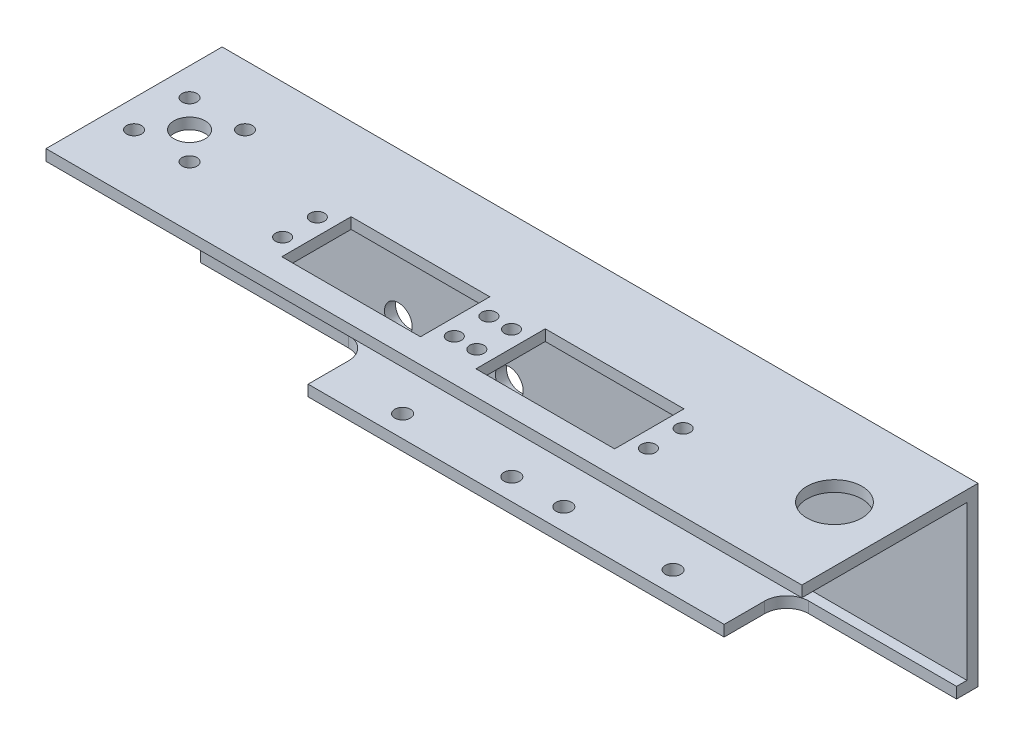
from build123d import *

# Parameters (mm, degrees)
BASE_ANGLE_PROFILE_DEPTH         = 109
SKETCH2_R                        = 2.05
SKETCH2_W                        = 40
SKETCH2_H                        = 20
SERVO_MOUNT_PATTERN_DEPTH        = 3.175
SKETCH3_R                        = 4.5
SKETCH3_R_2                      = 2.15
LEAD_SCREW_NUT_PATTERN_DEPTH     = 3.175
SKETCH4_R                        = 7.9375
SUPPORT_SHAFT_PASS_THROUGH_DEPTH = 3.175
CHANNEL_BOTTOM_CUT_DEPTH         = 10
SKETCH7_R                        = 4
CUT_EXTRUDE5_DEPTH               = 4.175
SKETCH8_R                        = 2.25
CUT_EXTRUDE6_DEPTH               = 3.175
FILLET1_R                        = 6.35
BODY_MOVE_COPY1_ANGLE            = 180


with BuildPart() as part:
    # Sketch1 → Base Angle Profile (new body, symmetric)
    with BuildSketch(Plane(origin=(0, 0, 0), x_dir=(0, 0, -1), z_dir=(1, 0, 0))):
        Polygon((0, 0), (50.8, 0), (50.8, -3.175), (3.175, -3.175), (3.175, -47.625), (50.8, -47.625), (50.8, -50.8), (0, -50.8), align=None)
    extrude(amount=BASE_ANGLE_PROFILE_DEPTH, both=True)

    # Sketch2 → Servo Mount Pattern (cut)
    with BuildSketch(Plane(origin=(0, 0, 0), x_dir=(1, 0, 0), z_dir=(0, 1, 0))):
        with Locations((-52.75, 38.8)):
            Circle(SKETCH2_R)
        with Locations((-52.75, 28.8)):
            Circle(SKETCH2_R)
        with Locations((-3.25, 38.8)):
            Circle(SKETCH2_R)
        with Locations((-3.25, 28.8)):
            Circle(SKETCH2_R)
        with Locations((3.25, 28.8)):
            Circle(SKETCH2_R)
        with Locations((3.25, 38.8)):
            Circle(SKETCH2_R)
        with Locations((52.75, 38.8)):
            Circle(SKETCH2_R)
        with Locations((52.75, 28.8)):
            Circle(SKETCH2_R)
        with Locations((-28, 33.8)):
            Rectangle(SKETCH2_W, SKETCH2_H)
        with Locations((28, 33.8)):
            Rectangle(SKETCH2_W, SKETCH2_H)
    extrude(amount=-SERVO_MOUNT_PATTERN_DEPTH, mode=Mode.SUBTRACT)

    # Sketch3 → Lead Screw Nut Pattern (cut)
    with BuildSketch(Plane(origin=(0, 0, 0), x_dir=(1, 0, 0), z_dir=(0, 1, 0))):
        with Locations((93, 25.4)):
            Circle(SKETCH3_R)
        with Locations((101, 33.4)):
            Circle(SKETCH3_R_2)
        with Locations((85, 33.4)):
            Circle(SKETCH3_R_2)
        with Locations((85, 17.4)):
            Circle(SKETCH3_R_2)
        with Locations((101, 17.4)):
            Circle(SKETCH3_R_2)
    extrude(amount=-LEAD_SCREW_NUT_PATTERN_DEPTH, mode=Mode.SUBTRACT)

    # Sketch4 → Support Shaft Pass Through (cut)
    with BuildSketch(Plane(origin=(0, 0, 0), x_dir=(1, 0, 0), z_dir=(0, 1, 0))):
        with Locations((-93, 25.4)):
            Circle(SKETCH4_R)
    extrude(amount=-SUPPORT_SHAFT_PASS_THROUGH_DEPTH, mode=Mode.SUBTRACT)

    # Sketch5 → Channel Bottom Cut (cut)
    with BuildSketch(Plane.XZ.offset(50.8)):
        Polygon((-109, -6.175), (-60, -6.175), (-60, -24.205), (60, -24.205), (60, -6.175), (109, -6.175), (109, -50.8), (-109, -50.8), align=None)
    extrude(amount=-CHANNEL_BOTTOM_CUT_DEPTH, mode=Mode.SUBTRACT)

    # Sketch7 → Cut-Extrude5 (cut, through all)
    with BuildSketch(Plane(origin=(0, 0, -3.175), x_dir=(-1, 0, 0), z_dir=(0, 0, -1))):
        with Locations((-55, -39.295)):
            Circle(SKETCH7_R)
        with Locations((-23, -39.295)):
            Circle(SKETCH7_R)
        with Locations((23, -39.295)):
            Circle(SKETCH7_R)
        with Locations((55, -39.295)):
            Circle(SKETCH7_R)
    extrude(amount=-CUT_EXTRUDE5_DEPTH, mode=Mode.SUBTRACT)

    # Sketch8 → Cut-Extrude6 (cut)
    with BuildSketch(Plane(origin=(0, -50.8, 0), x_dir=(-1, 0, 0), z_dir=(0, -1, 0))):
        with Locations((39, 17.955)):
            Circle(SKETCH8_R)
        with Locations((7.5, 17.955)):
            Circle(SKETCH8_R)
        with Locations((-7.5, 17.955)):
            Circle(SKETCH8_R)
        with Locations((-39, 17.955)):
            Circle(SKETCH8_R)
    extrude(amount=-CUT_EXTRUDE6_DEPTH, mode=Mode.SUBTRACT)

    # Fillet1
    fillet1_edges = [part.edges().sort_by_distance(p)[0] for p in [
        (-60, -49.2125, -6.175),
        (60, -49.2125, -6.175),
    ]]
    fillet(fillet1_edges, radius=FILLET1_R)


with BuildPart() as part_1:
    # Body-Move/Copy1: moved
    add(part.part.rotate(Axis((0, 0, -25.4), (0, 1, 0)), BODY_MOVE_COPY1_ANGLE))


solid = part_1.part
